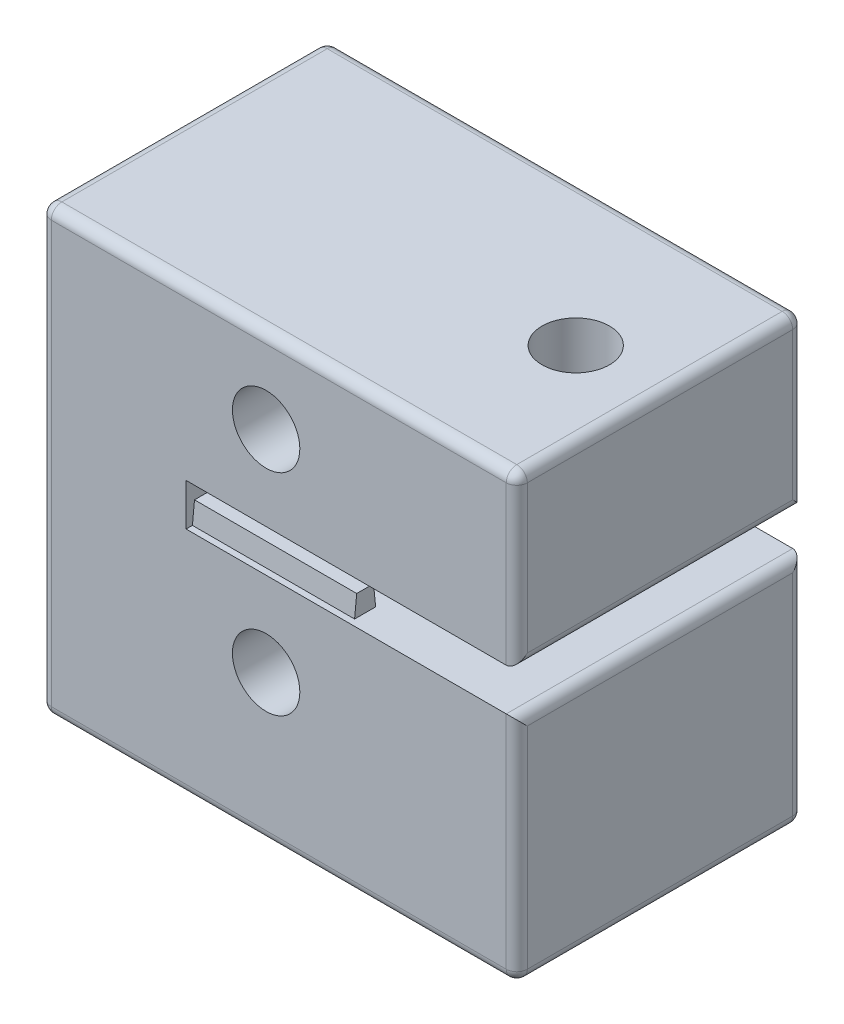
from build123d import *

# Parameters (mm, degrees)
SKETCH1_R               = 1.6
SKETCH1_R_2             = 5.7
BOSS_EXTRUDE1_DEPTH     = 16
SKETCH2_R               = 1.6
CUT_EXTRUDE1_DEPTH      = 18.4
SKETCH3_W               = 8
SKETCH3_H               = 4
CUT_EXTRUDE2_DEPTH      = 14.9
SKETCH4_R               = 2.6
CUT_EXTRUDE3_DEPTH      = 25
SKETCH5_R               = 6
CUT_EXTRUDE4_DEPTH      = 6
SKETCH6_R               = 4.025
CUT_EXTRUDE5_DEPTH      = 17.4
SKETCH7_R               = 7.95
CUT_EXTRUDE6_DEPTH      = 11
SKETCH8_R               = 7.95
CUT_EXTRUDE7_DEPTH      = 11
BOSS_EXTRUDE2_DEPTH     = 7.7
SKETCH10_R              = 1.6
CUT_EXTRUDE8_DEPTH      = 21
CUT_EXTRUDE9_DEPTH      = 20
CUT_EXTRUDE9_DEPTH_BACK = 20
FILLET2_R               = 0.5


with BuildPart() as part:
    # Sketch1 → Boss-Extrude1 (new body, symmetric)
    with BuildSketch(Plane.XY):
        with BuildLine():
            Line((0, 0), (23, 0))
            Line((23, 0), (23, 11.85))
            Line((23, 11.85), (40, 11.85))
            Line((40, 11.85), (40, 22.85))
            Line((40, 22.85), (24.3, 22.85))
            Line((24.3, 22.85), (24.3, 24.85))
            Line((24.3, 24.85), (40, 24.85))
            Line((40, 24.85), (40, 32.85))
            Line((40, 32.85), (15.939721203, 32.85))
            ThreePointArc((15.939721203, 32.85), (-0.817389789, 43.335843617), (1.211999203, 23.672800478))
            ThreePointArc((1.211999203, 23.672800478), (2.953099737, 18.191047558), (0, 13.255437353))
            Line((0, 13.255437353), (0, 0))
        make_face()
        with Locations((28.1, 28.85)):
            Circle(SKETCH1_R, mode=Mode.SUBTRACT)
        with Locations((28.1, 18.85)):
            Circle(SKETCH1_R, mode=Mode.SUBTRACT)
        with Locations((5, 34)):
            Circle(SKETCH1_R_2, mode=Mode.SUBTRACT)
    extrude(amount=BOSS_EXTRUDE1_DEPTH, both=True)

    # Sketch2 → Cut-Extrude1 (cut)
    with BuildSketch(Plane(origin=(0, 0, -16), x_dir=(-1, 0, 0), z_dir=(0, 0, -1))):
        with BuildLine():
            Line((-23, 0), (-15, 0))
            Line((-15, 0), (-15, 16.5))
            Line((-15, 16.5), (-2.538348415, 16.5))
            ThreePointArc((-2.538348415, 16.5), (-2.706537293, 16.994418404), (-2.837397166, 17.5))
            Line((-2.837397166, 17.5), (-15, 17.5))
            Line((-15, 17.5), (-15, 29.417424305))
            ThreePointArc((-15, 29.417424305), (-15.609600605, 31.095456144), (-15.939721203, 32.85))
            Line((-15.939721203, 32.85), (-40, 32.85))
            Line((-40, 32.85), (-40, 24.85))
            Line((-40, 24.85), (-24.3, 24.85))
            Line((-24.3, 24.85), (-24.3, 22.85))
            Line((-24.3, 22.85), (-40, 22.85))
            Line((-40, 22.85), (-40, 11.85))
            Line((-40, 11.85), (-23, 11.85))
            Line((-23, 11.85), (-23, 0))
        make_face()
        with Locations((-28.1, 18.85)):
            Circle(SKETCH2_R, mode=Mode.SUBTRACT)
        with Locations((-28.1, 28.85)):
            Circle(SKETCH2_R, mode=Mode.SUBTRACT)
    extrude(amount=-CUT_EXTRUDE1_DEPTH, mode=Mode.SUBTRACT)

    # Sketch3 → Cut-Extrude2 (cut)
    with BuildSketch(Plane(origin=(0, 0, -16), x_dir=(-1, 0, 0), z_dir=(0, 0, -1))):
        with Locations((-8.7, 21.5)):
            Rectangle(SKETCH3_W, SKETCH3_H)
    extrude(amount=-CUT_EXTRUDE2_DEPTH, mode=Mode.SUBTRACT)

    # Sketch4 → Cut-Extrude3 (cut)
    with BuildSketch(Plane.XZ):
        with Locations((8.7, -7.6)):
            Circle(SKETCH4_R)
    extrude(amount=-CUT_EXTRUDE3_DEPTH, mode=Mode.SUBTRACT)

    # Sketch5 → Cut-Extrude4 (cut)
    with BuildSketch(Plane.XZ):
        with Locations((8.7, -7.6)):
            Circle(SKETCH5_R)
    extrude(amount=-CUT_EXTRUDE4_DEPTH, mode=Mode.SUBTRACT)

    # Sketch6 → Cut-Extrude5 (cut)
    with BuildSketch(Plane.ZY):
        with Locations((4.2, 17)):
            Circle(SKETCH6_R)
    extrude(amount=-CUT_EXTRUDE5_DEPTH, mode=Mode.SUBTRACT)

    # Sketch7 → Cut-Extrude6 (cut)
    with BuildSketch(Plane(origin=(0, 0, -16), x_dir=(-1, 0, 0), z_dir=(0, 0, -1))):
        with Locations((-5, 34)):
            Circle(SKETCH7_R)
    extrude(amount=-CUT_EXTRUDE6_DEPTH, mode=Mode.SUBTRACT)

    # Sketch8 → Cut-Extrude7 (cut)
    with BuildSketch(Plane.XY.offset(16)):
        with Locations((5, 34)):
            Circle(SKETCH8_R)
    extrude(amount=-CUT_EXTRUDE7_DEPTH, mode=Mode.SUBTRACT)

    # Sketch9 → Boss-Extrude2 (add)
    with BuildSketch(Plane(origin=(24.3, 0, 0), x_dir=(0, 0, -1), z_dir=(1, 0, 0))):
        Polygon((-15.7, 22.85), (-14.7, 22.85), (-14.8, 23.85), (-15.6, 23.85), align=None)
        Polygon((-13.6, 23.85), (-13.7, 22.85), (-12.7, 22.85), (-12.8, 23.85), align=None)
        Polygon((-11.6, 23.85), (-11.7, 22.85), (-10.7, 22.85), (-10.8, 23.85), align=None)
        Polygon((-9.6, 23.85), (-9.7, 22.85), (-8.7, 22.85), (-8.8, 23.85), align=None)
        Polygon((-7.6, 23.85), (-7.7, 22.85), (-6.7, 22.85), (-6.8, 23.85), align=None)
        Polygon((-5.6, 23.85), (-5.7, 22.85), (-4.7, 22.85), (-4.8, 23.85), align=None)
        Polygon((-3.6, 23.85), (-3.7, 22.85), (-2.7, 22.85), (-2.8, 23.85), align=None)
    extrude(amount=BOSS_EXTRUDE2_DEPTH)

    # Sketch10 → Cut-Extrude8 (cut)
    with BuildSketch(Plane(origin=(0, 32.85, 0), x_dir=(1, 0, 0), z_dir=(0, 1, 0))):
        with Locations((36, -9.2)):
            Circle(SKETCH10_R)
    extrude(amount=-CUT_EXTRUDE8_DEPTH, mode=Mode.SUBTRACT)

    # Sketch11 → Cut-Extrude9 (cut, two sides)
    with BuildSketch(Plane(origin=(0, 0, 2.4), x_dir=(-1, 0, 0), z_dir=(0, 0, -1))) as cut_extrude9_sk:
        Polygon((-23, 11.85), (-17.4, 11.85), (-17.4, 32.85), (-17.4, 56.269186849), (20.068849224, 56.269186849), (20.068849224, -12.231640917), (-23, -11.328049524), (-29.029830536, 8.113428838), align=None)
    extrude(amount=CUT_EXTRUDE9_DEPTH, mode=Mode.SUBTRACT)
    extrude(cut_extrude9_sk.sketch, amount=-CUT_EXTRUDE9_DEPTH_BACK, mode=Mode.SUBTRACT)

    # Fillet2
    fillet2_edges = [part.edges().sort_by_distance(p)[0] for p in [
        (28.7, 11.85, 16),
        (17.4, 22.35, 2.4),
        (40, 17.35, 16),
        (40, 32.85, 9.2),
        (40, 24.85, 9.2),
        (40, 22.85, 9.2),
        (40, 11.85, 9.2),
        (28.7, 32.85, 2.4),
        (17.4, 32.85, 9.2),
        (17.4, 22.35, 16),
        (17.4, 11.85, 9.2),
        (40, 28.85, 16),
        (28.7, 32.85, 16),
        (28.7, 11.85, 2.4),
        (40, 17.35, 2.4),
        (40, 28.85, 2.4),
    ]]
    fillet(fillet2_edges, radius=FILLET2_R)


solid = part.part
